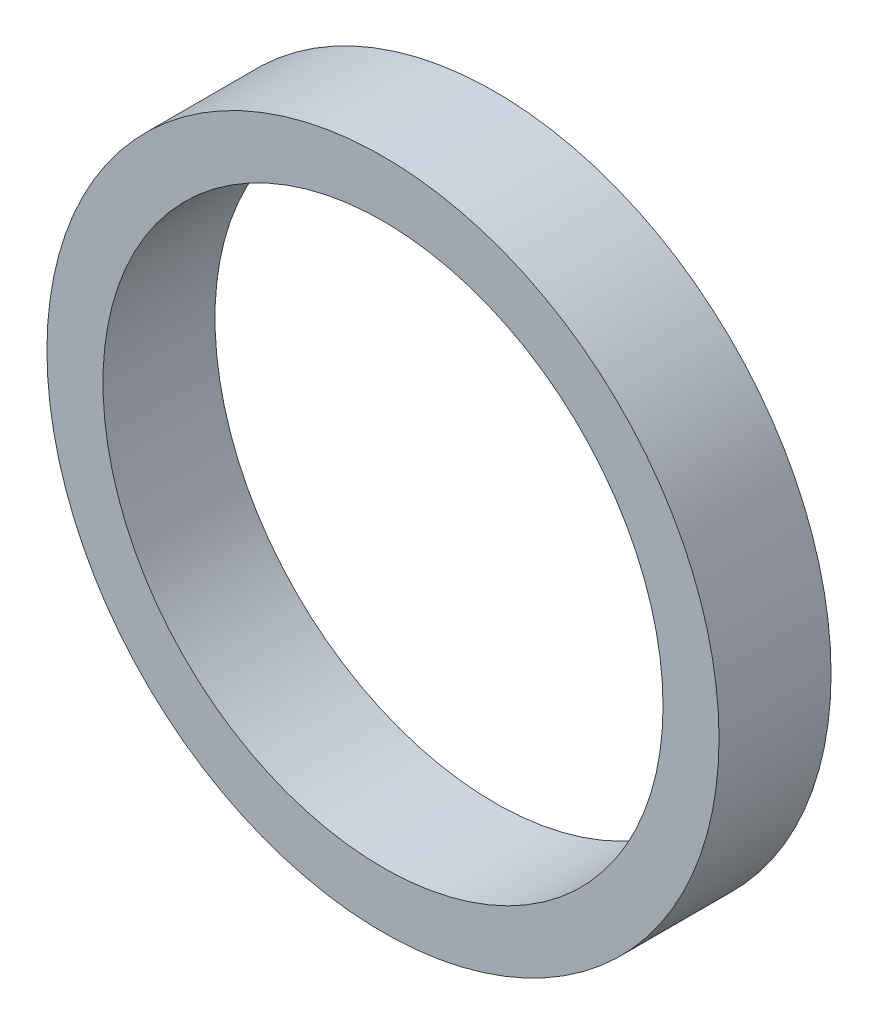
from build123d import *

# Parameters (mm, degrees)
SKETCH1_R           = 30
SKETCH1_R_2         = 25
BOSS_EXTRUDE1_DEPTH = 10


with BuildPart() as part:
    # Sketch1 → Boss-Extrude1 (new body)
    with BuildSketch(Plane.XY):
        Circle(SKETCH1_R)
        Circle(SKETCH1_R_2, mode=Mode.SUBTRACT)
    extrude(amount=BOSS_EXTRUDE1_DEPTH)


solid = part.part
